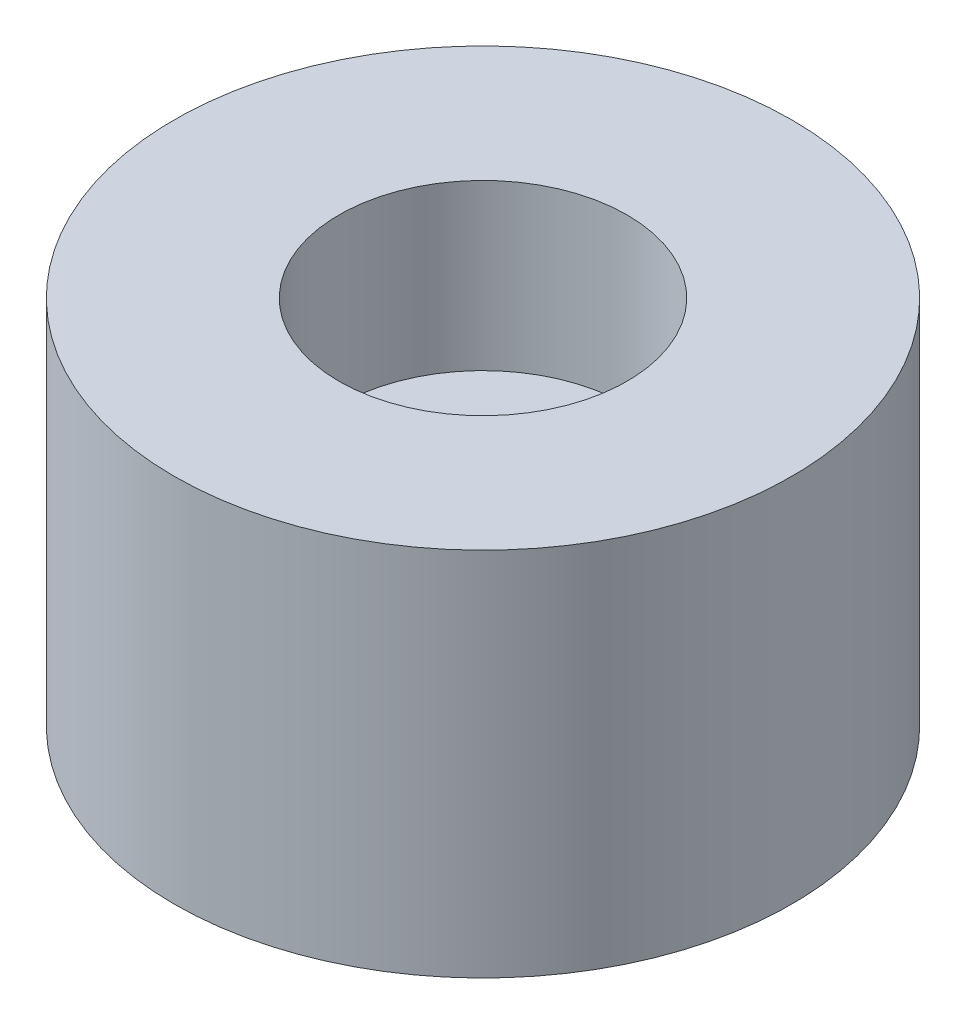
from build123d import *


with BuildPart() as part:
    # Sketch1 → Revolve1 (revolve)
    with BuildSketch(Plane.XY):
        Polygon((3.5, 9), (3.5, 5), (1.75, 5), (1.75, 0), (7.5, 0), (7.5, 9), align=None)
    revolve(axis=Axis((0, 0, 0), (0, 1, 0)))


solid = part.part
